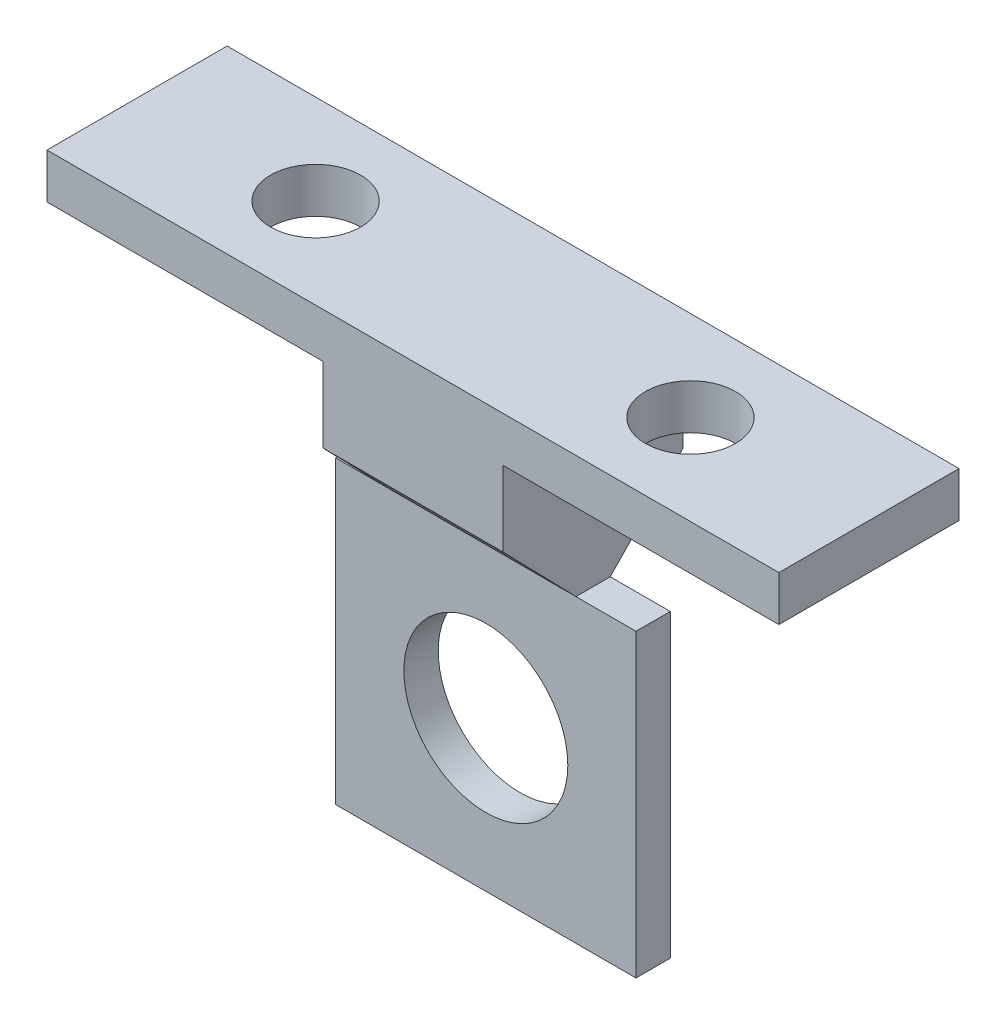
from build123d import *

# Parameters (mm, degrees)
SALIENTE_EXTRUIR1_DEPTH = 2.286
CROQUIS3_W              = 12
CROQUIS3_H              = 3
SALIENTE_EXTRUIR2_DEPTH = 48.748737
SALIENTE_EXTRUIR3_DEPTH = 12
CROQUIS5_R              = 5.46
CORTAR_EXTRUIR1_DEPTH   = 8.143
CROQUIS6_R              = 3
CORTAR_EXTRUIR2_DEPTH   = 3


with BuildPart() as part:
    # Croquis1 → Saliente-Extruir1 (new body)
    with BuildSketch(Plane.XY):
        Polygon((-14.666527812, 16.476832902), (-63.415265152, 16.476832902), (-63.415265152, 13.476832902), (-45.040896482, 13.476832902), (-45.040896482, 8.476832902), (-45.040896482, 3.476832902), (-49.040896482, 3.476832902), (-49.040896482, -16.523167098), (-29.040896482, -16.523167098), (-29.040896482, 3.476832902), (-33.040896482, 3.476832902), (-33.040896482, 8.476832902), (-33.040896482, 13.476832902), (-14.666527812, 13.476832902), align=None)
    extrude(amount=SALIENTE_EXTRUIR1_DEPTH)

    # Croquis3 → Saliente-Extruir2 (add)
    with BuildSketch(Plane.ZY.offset(63.415265152)):
        with Locations((1.143, 14.976832902)):
            Rectangle(CROQUIS3_W, CROQUIS3_H)
    extrude(amount=-SALIENTE_EXTRUIR2_DEPTH)

    # Croquis4 → Saliente-Extruir3 (add)
    with BuildSketch(Plane(origin=(-33.040896482, 0, 0), x_dir=(0, 0, -1), z_dir=(1, 0, 0))):
        Polygon((4.857, 8.476832902), (0, 3.476832902), (-2.286, 3.476832902), (-7.143, 8.476832902), (-7.143, 13.476832902), (4.857, 13.476832902), align=None)
    extrude(amount=-SALIENTE_EXTRUIR3_DEPTH)

    # Croquis5 → Cortar-Extruir1 (cut, through all)
    with BuildSketch(Plane.XY.offset(2.286)):
        with Locations((-39.040896482, -6.523167098)):
            Circle(CROQUIS5_R)
    extrude(amount=-CORTAR_EXTRUIR1_DEPTH, mode=Mode.SUBTRACT)

    # Croquis6 → Cortar-Extruir2 (cut)
    with BuildSketch(Plane(origin=(0, 16.476832902, 0), x_dir=(1, 0, 0), z_dir=(0, 1, 0))):
        with Locations((-26.558072422, -1.143)):
            Circle(CROQUIS6_R)
        with Locations((-51.523720542, -1.143)):
            Circle(CROQUIS6_R)
    extrude(amount=-CORTAR_EXTRUIR2_DEPTH, mode=Mode.SUBTRACT)


solid = part.part
